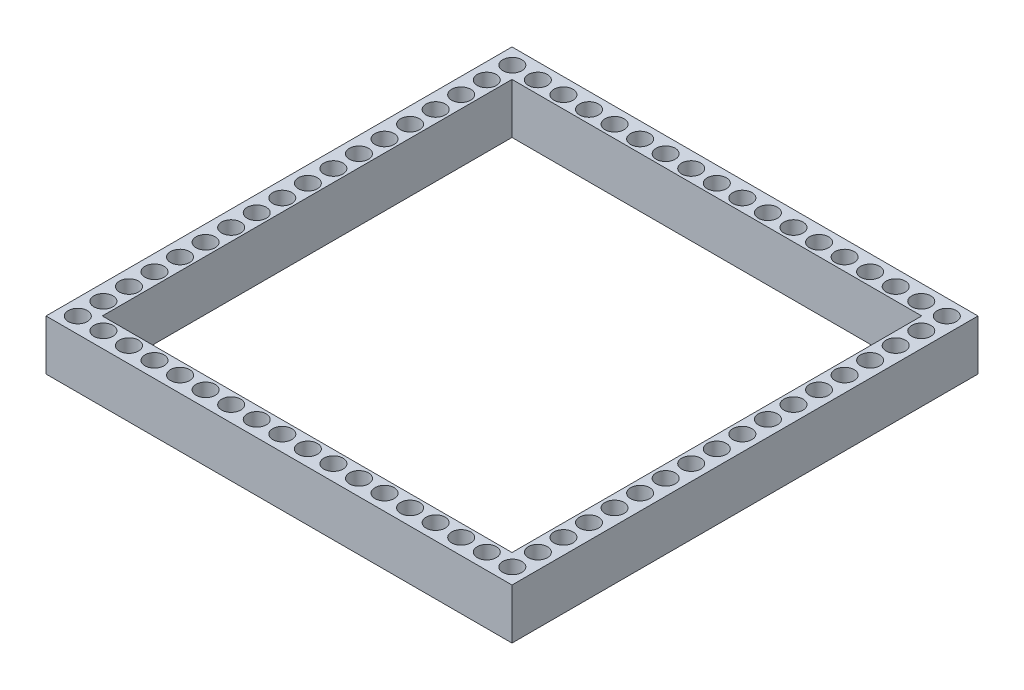
from build123d import *

# Parameters (mm, degrees)
SKETCH2_W           = 46.3108
SKETCH2_H           = 46.3108
SKETCH2_W_2         = 40.7172
SKETCH2_H_2         = 40.7172
BOSS_EXTRUDE1_DEPTH = 5
SKETCH1_R           = 0.95
CUT_EXTRUDE1_DEPTH  = 6


with BuildPart() as part:
    # Sketch2 → Boss-Extrude1 (new body)
    with BuildSketch(Plane(origin=(0, 0, 0), x_dir=(1, 0, 0), z_dir=(0, 1, 0))):
        Rectangle(SKETCH2_W, SKETCH2_H)
        Rectangle(SKETCH2_W_2, SKETCH2_H_2, mode=Mode.SUBTRACT)
    extrude(amount=BOSS_EXTRUDE1_DEPTH)

    # Sketch1 → Cut-Extrude1 (cut, through all)
    with BuildSketch(Plane(origin=(0, 0, 0), x_dir=(1, 0, 0), z_dir=(0, 1, 0))):
        with Locations((-21.5644, 21.5964)):
            Circle(SKETCH1_R)
        with Locations((-19.0244, 21.5964)):
            Circle(SKETCH1_R)
        with Locations((-21.5644, 19.0564)):
            Circle(SKETCH1_R)
        with Locations((-16.4844, 21.5964)):
            Circle(SKETCH1_R)
        with Locations((-13.9444, 21.5964)):
            Circle(SKETCH1_R)
        with Locations((-11.4044, 21.5964)):
            Circle(SKETCH1_R)
        with Locations((-8.8644, 21.5964)):
            Circle(SKETCH1_R)
        with Locations((-6.3244, 21.5964)):
            Circle(SKETCH1_R)
        with Locations((-3.7844, 21.5964)):
            Circle(SKETCH1_R)
        with Locations((-1.2444, 21.5964)):
            Circle(SKETCH1_R)
        with Locations((1.2956, 21.5964)):
            Circle(SKETCH1_R)
        with Locations((3.8356, 21.5964)):
            Circle(SKETCH1_R)
        with Locations((6.3756, 21.5964)):
            Circle(SKETCH1_R)
        with Locations((8.9156, 21.5964)):
            Circle(SKETCH1_R)
        with Locations((11.4556, 21.5964)):
            Circle(SKETCH1_R)
        with Locations((13.9956, 21.5964)):
            Circle(SKETCH1_R)
        with Locations((16.5356, 21.5964)):
            Circle(SKETCH1_R)
        with Locations((19.0756, 21.5964)):
            Circle(SKETCH1_R)
        with Locations((21.6156, 21.5964)):
            Circle(SKETCH1_R)
        with Locations((-21.5644, 16.5164)):
            Circle(SKETCH1_R)
        with Locations((-21.5644, 13.9764)):
            Circle(SKETCH1_R)
        with Locations((-21.5644, 11.4364)):
            Circle(SKETCH1_R)
        with Locations((-21.5644, 8.8964)):
            Circle(SKETCH1_R)
        with Locations((-21.5644, 6.3564)):
            Circle(SKETCH1_R)
        with Locations((-21.5644, 3.8164)):
            Circle(SKETCH1_R)
        with Locations((-21.5644, 1.2764)):
            Circle(SKETCH1_R)
        with Locations((-21.5644, -1.2636)):
            Circle(SKETCH1_R)
        with Locations((-21.5644, -3.8036)):
            Circle(SKETCH1_R)
        with Locations((-21.5644, -6.3436)):
            Circle(SKETCH1_R)
        with Locations((-21.5644, -8.8836)):
            Circle(SKETCH1_R)
        with Locations((-21.5644, -11.4236)):
            Circle(SKETCH1_R)
        with Locations((-21.5644, -13.9636)):
            Circle(SKETCH1_R)
        with Locations((-21.5644, -16.5036)):
            Circle(SKETCH1_R)
        with Locations((-21.5644, -19.0436)):
            Circle(SKETCH1_R)
        with Locations((-21.5644, -21.5836)):
            Circle(SKETCH1_R)
        with Locations((-19.0244, -21.5836)):
            Circle(SKETCH1_R)
        with Locations((-16.4844, -21.5836)):
            Circle(SKETCH1_R)
        with Locations((-13.9444, -21.5836)):
            Circle(SKETCH1_R)
        with Locations((-11.4044, -21.5836)):
            Circle(SKETCH1_R)
        with Locations((-8.8644, -21.5836)):
            Circle(SKETCH1_R)
        with Locations((-6.3244, -21.5836)):
            Circle(SKETCH1_R)
        with Locations((-3.7844, -21.5836)):
            Circle(SKETCH1_R)
        with Locations((-1.2444, -21.5836)):
            Circle(SKETCH1_R)
        with Locations((1.2956, -21.5836)):
            Circle(SKETCH1_R)
        with Locations((3.8356, -21.5836)):
            Circle(SKETCH1_R)
        with Locations((6.3756, -21.5836)):
            Circle(SKETCH1_R)
        with Locations((8.9156, -21.5836)):
            Circle(SKETCH1_R)
        with Locations((11.4556, -21.5836)):
            Circle(SKETCH1_R)
        with Locations((13.9956, -21.5836)):
            Circle(SKETCH1_R)
        with Locations((16.5356, -21.5836)):
            Circle(SKETCH1_R)
        with Locations((19.0756, -21.5836)):
            Circle(SKETCH1_R)
        with Locations((21.6156, -21.5836)):
            Circle(SKETCH1_R)
        with Locations((21.6156, 19.0564)):
            Circle(SKETCH1_R)
        with Locations((21.6156, 16.5164)):
            Circle(SKETCH1_R)
        with Locations((21.6156, 11.4364)):
            Circle(SKETCH1_R)
        with Locations((21.6156, 8.8964)):
            Circle(SKETCH1_R)
        with Locations((21.6156, 6.3564)):
            Circle(SKETCH1_R)
        with Locations((21.6156, 3.8164)):
            Circle(SKETCH1_R)
        with Locations((21.6156, 1.2764)):
            Circle(SKETCH1_R)
        with Locations((21.6156, -1.2636)):
            Circle(SKETCH1_R)
        with Locations((21.6156, -3.8036)):
            Circle(SKETCH1_R)
        with Locations((21.6156, -6.3436)):
            Circle(SKETCH1_R)
        with Locations((21.6156, -8.8836)):
            Circle(SKETCH1_R)
        with Locations((21.6156, -11.4236)):
            Circle(SKETCH1_R)
        with Locations((21.6156, -13.9636)):
            Circle(SKETCH1_R)
        with Locations((21.6156, -16.5036)):
            Circle(SKETCH1_R)
        with Locations((21.6156, -19.0436)):
            Circle(SKETCH1_R)
        with Locations((21.6156, 13.9764)):
            Circle(SKETCH1_R)
    extrude(amount=CUT_EXTRUDE1_DEPTH, mode=Mode.SUBTRACT)


solid = part.part
